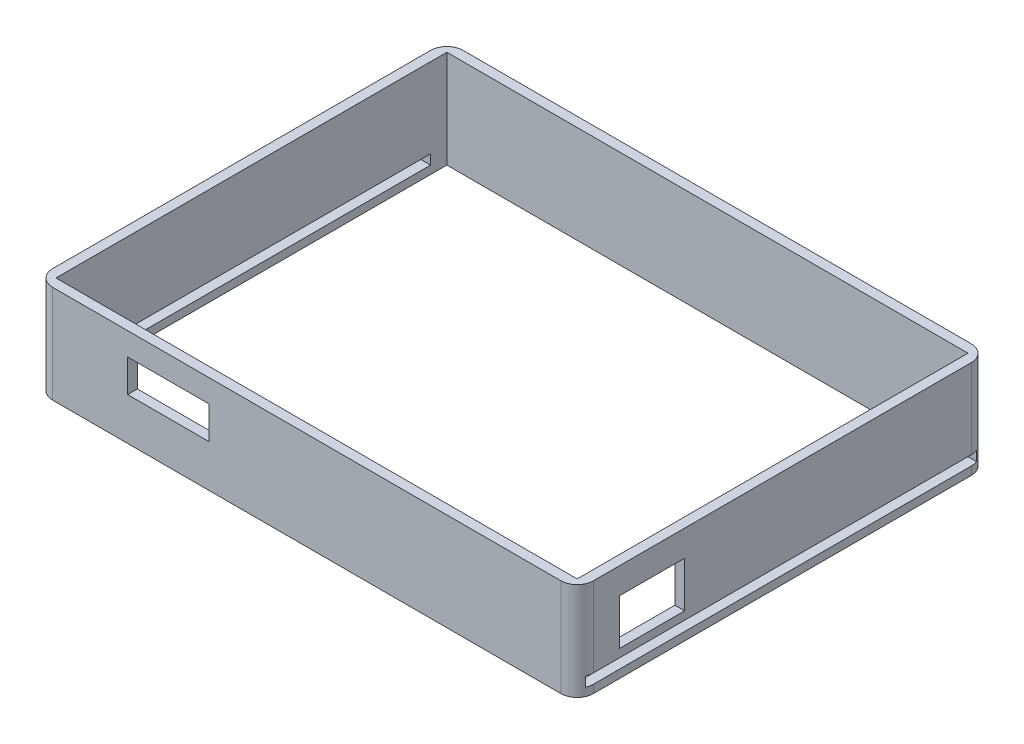
from build123d import *

# Parameters (mm, degrees)
SKETCH_1_W          = 166
SKETCH_1_H          = 126
SKETCH_1_W_2        = 160
SKETCH_1_H_2        = 120
EXTRUDE_1_DEPTH     = 30
FILLET_1_R          = 5
SKETCH_2_W          = 25
SKETCH_2_H          = 10
CUT_EXTRUDE_1_DEPTH = 100
SKETCH_3_W          = 20
SKETCH_3_H          = 14
CUT_EXTRUDE_2_DEPTH = 100
SKETCH_4_W          = 120
SKETCH_4_H          = 3
CUT_EXTRUDE_3_DEPTH = 100
SKETCH_5_W          = 110
SKETCH_5_H          = 3
CUT_EXTRUDE_4_DEPTH = 100


with BuildPart() as part:
    # 草图1 → 凸台-拉伸1 (new body)
    with BuildSketch(Plane(origin=(0, 0, 0), x_dir=(1, 0, 0), z_dir=(0, 1, 0))):
        Rectangle(SKETCH_1_W, SKETCH_1_H)
        Rectangle(SKETCH_1_W_2, SKETCH_1_H_2, mode=Mode.SUBTRACT)
    extrude(amount=EXTRUDE_1_DEPTH)

    # 圆角1
    fillet_1_edges = [part.edges().sort_by_distance(p)[0] for p in [
        (83, 15, 63),
        (-83, 15, 63),
        (-83, 15, -63),
        (83, 15, -63),
    ]]
    fillet(fillet_1_edges, radius=FILLET_1_R)

    # 草图2 → 切除-拉伸1 (cut)
    with BuildSketch(Plane.XY):
        with Locations((-42.5, 18)):
            Rectangle(SKETCH_2_W, SKETCH_2_H)
    extrude(amount=CUT_EXTRUDE_1_DEPTH, mode=Mode.SUBTRACT)

    # 草图3 → 切除-拉伸2 (cut)
    with BuildSketch(Plane(origin=(0, 0, 0), x_dir=(0, 0, -1), z_dir=(1, 0, 0))):
        with Locations((-40, 15)):
            Rectangle(SKETCH_3_W, SKETCH_3_H)
    extrude(amount=CUT_EXTRUDE_2_DEPTH, mode=Mode.SUBTRACT)

    # 草图4 → 切除-拉伸3 (cut)
    with BuildSketch(Plane(origin=(0, 0, 0), x_dir=(0, 0, -1), z_dir=(1, 0, 0))):
        with Locations((0, 4)):
            Rectangle(SKETCH_4_W, SKETCH_4_H)
    extrude(amount=CUT_EXTRUDE_3_DEPTH, mode=Mode.SUBTRACT)

    # 草图5 → 切除-拉伸4 (cut)
    with BuildSketch(Plane(origin=(0, 0, 0), x_dir=(0, 0, -1), z_dir=(1, 0, 0))):
        with Locations((0, 4)):
            Rectangle(SKETCH_5_W, SKETCH_5_H)
    extrude(amount=-CUT_EXTRUDE_4_DEPTH, mode=Mode.SUBTRACT)


solid = part.part
